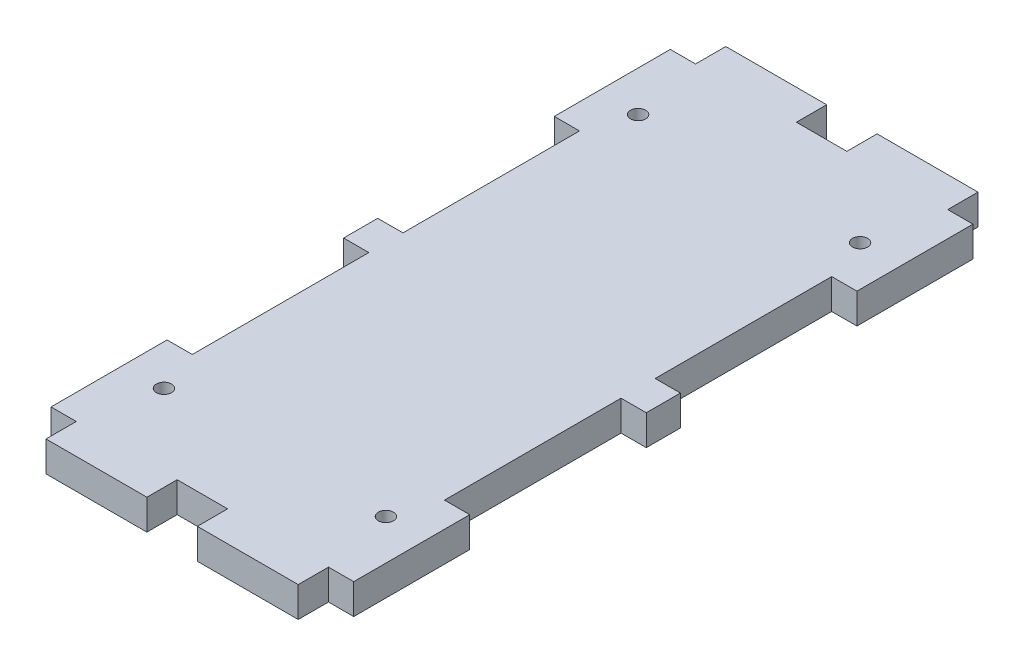
from build123d import *

# Parameters (mm, degrees)
ESQUISSE1_W             = 60
ESQUISSE1_H             = 122.76
BOSS_EXTRU_1_DEPTH      = 6
ESQUISSE2_W             = 20
ESQUISSE2_H             = 6
BOSS_EXTRU_2_DEPTH      = 6
ESQUISSE3_R             = 1.5
ENL_V_MAT_EXTRU_1_DEPTH = 6
ESQUISSE4_W             = 5
ESQUISSE4_H             = 35
ENL_V_MAT_EXTRU_2_DEPTH = 6


with BuildPart() as part:
    # Esquisse1 → Boss.-Extru.1 (new body)
    with BuildSketch(Plane(origin=(0, 0, 0), x_dir=(1, 0, 0), z_dir=(0, 1, 0))):
        Rectangle(ESQUISSE1_W, ESQUISSE1_H)
    extrude(amount=BOSS_EXTRU_1_DEPTH)

    # Esquisse2 → Boss.-Extru.2 (add)
    with BuildSketch(Plane(origin=(0, 6, 0), x_dir=(1, 0, 0), z_dir=(0, 1, 0))):
        with Locations((-15, 64.38)):
            Rectangle(ESQUISSE2_W, ESQUISSE2_H)
        with Locations((15, 64.38)):
            Rectangle(ESQUISSE2_W, ESQUISSE2_H)
        with Locations((15, -64.38)):
            Rectangle(ESQUISSE2_W, ESQUISSE2_H)
        with Locations((-15, -64.38)):
            Rectangle(ESQUISSE2_W, ESQUISSE2_H)
    extrude(amount=-BOSS_EXTRU_2_DEPTH)

    # Esquisse3 → Enlèv. mat.-Extru.1 (cut)
    with BuildSketch(Plane(origin=(0, 6, 0), x_dir=(1, 0, 0), z_dir=(0, 1, 0))):
        with Locations((22, 47)):
            Circle(ESQUISSE3_R)
        with Locations((-22, 47)):
            Circle(ESQUISSE3_R)
        with Locations((-22, -47)):
            Circle(ESQUISSE3_R)
        with Locations((22, -47)):
            Circle(ESQUISSE3_R)
    extrude(amount=-ENL_V_MAT_EXTRU_1_DEPTH, mode=Mode.SUBTRACT)

    # Esquisse4 → Enlèv. mat.-Extru.2 (cut)
    with BuildSketch(Plane(origin=(0, 6, 0), x_dir=(1, 0, 0), z_dir=(0, 1, 0))):
        with Locations((-27.5, -20.88)):
            Rectangle(ESQUISSE4_W, ESQUISSE4_H)
        with Locations((27.5, -20.88)):
            Rectangle(ESQUISSE4_W, ESQUISSE4_H)
        with Locations((-27.5, 20.88)):
            Rectangle(ESQUISSE4_W, ESQUISSE4_H)
        with Locations((27.5, 20.88)):
            Rectangle(ESQUISSE4_W, ESQUISSE4_H)
    extrude(amount=-ENL_V_MAT_EXTRU_2_DEPTH, mode=Mode.SUBTRACT)


solid = part.part
